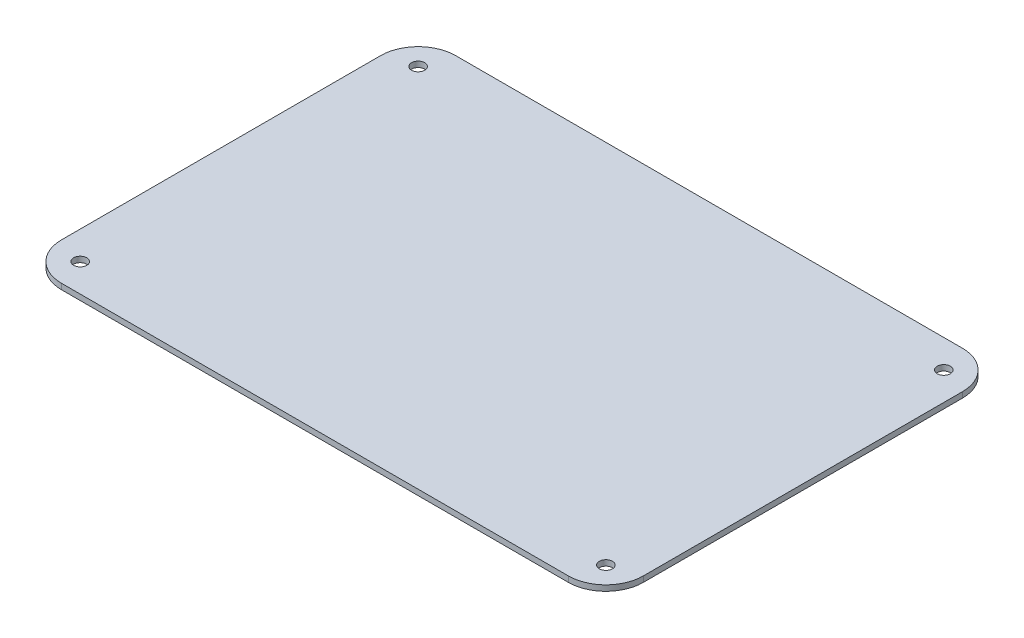
from build123d import *

# Parameters (mm, degrees)
SKETCH1_W           = 310
SKETCH1_H           = 210
SKETCH1_R           = 3.5
BOSS_EXTRUDE1_DEPTH = 3
FILLET1_R           = 20


with BuildPart() as part:
    # Sketch1 → Boss-Extrude1 (new body)
    with BuildSketch(Plane(origin=(0, 0, 0), x_dir=(1, 0, 0), z_dir=(0, 1, 0))):
        Rectangle(SKETCH1_W, SKETCH1_H)
        with Locations((-140, 90)):
            Circle(SKETCH1_R, mode=Mode.SUBTRACT)
        with Locations((140, 90)):
            Circle(SKETCH1_R, mode=Mode.SUBTRACT)
        with Locations((140, -90)):
            Circle(SKETCH1_R, mode=Mode.SUBTRACT)
        with Locations((-140, -90)):
            Circle(SKETCH1_R, mode=Mode.SUBTRACT)
    extrude(amount=BOSS_EXTRUDE1_DEPTH)

    # Fillet1
    fillet1_edges = [part.edges().sort_by_distance(p)[0] for p in [
        (-155, 1.5, -105),
        (155, 1.5, -105),
        (155, 1.5, 105),
        (-155, 1.5, 105),
    ]]
    fillet(fillet1_edges, radius=FILLET1_R)


solid = part.part
